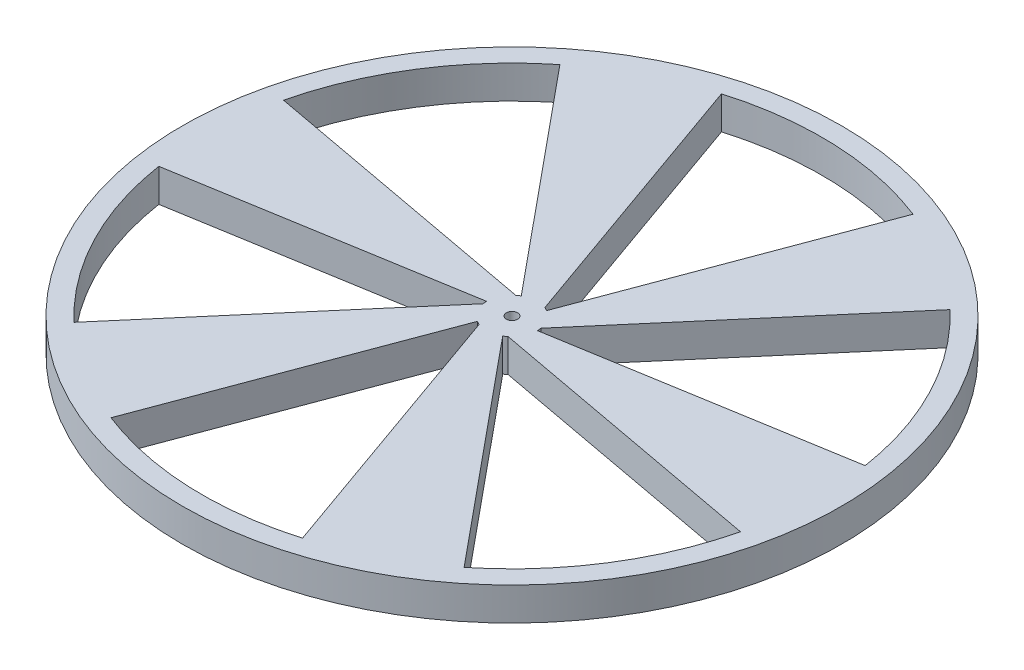
from build123d import *

# Parameters (mm, degrees)
SKETCH1_R           = 50
SKETCH1_R_2         = 47
SKETCH1_R_3         = 3.85
SKETCH1_R_4         = 0.85
BOSS_EXTRUDE1_DEPTH = 5


with BuildPart() as part:
    # Sketch1 → Boss-Extrude1 (new body)
    with BuildSketch(Plane(origin=(0, 0, 0), x_dir=(1, 0, 0), z_dir=(0, 1, 0))):
        Circle(SKETCH1_R)
        Circle(SKETCH1_R_2, mode=Mode.SUBTRACT)
        Circle(SKETCH1_R_3)
        Circle(SKETCH1_R_4, mode=Mode.SUBTRACT)
        with BuildLine():
            ThreePointArc((1.925, -3.334197805), (0.295727162, -3.838625463), (-1.39158336, -3.589706917))
            Line((-1.39158336, -3.589706917), (13.299862292, -45.078971406))
            ThreePointArc((13.299862292, -45.078971406), (21.761273299, -41.658696384), (29.402141879, -36.667615861))
            Line((29.402141879, -36.667615861), (1.925, -3.334197805))
        make_face()
        with BuildLine():
            Line((46.456157771, 7.129193862), (3.85, 0))
            ThreePointArc((3.85, 0), (3.472210748, -1.663205496), (2.412985702, -3))
            Line((2.412985702, -3), (45.68946556, -11.021467091))
            ThreePointArc((45.68946556, -11.021467091), (46.671216404, -5.549554878), (47, 0))
            ThreePointArc((47, 0), (46.86384222, 3.574953479), (46.456157771, 7.129193862))
        make_face()
        with BuildLine():
            Line((17.054015892, 43.796809723), (1.925, 3.334197805))
            ThreePointArc((1.925, 3.334197805), (3.176483585, 2.175419967), (3.804569063, 0.589706917))
            Line((3.804569063, 0.589706917), (32.389603268, 34.057504315))
            ThreePointArc((32.389603268, 34.057504315), (25.196852708, 39.675163687), (17.054015892, 43.796809723))
        make_face()
        with BuildLine():
            Line((-29.402141879, 36.667615861), (-1.925, 3.334197805))
            ThreePointArc((-1.925, 3.334197805), (-0.295727162, 3.838625463), (1.39158336, 3.589706917))
            Line((1.39158336, 3.589706917), (-13.299862292, 45.078971406))
            ThreePointArc((-13.299862292, 45.078971406), (-21.761273299, 41.658696384), (-29.402141879, 36.667615861))
        make_face()
        with BuildLine():
            ThreePointArc((-3.85, 0), (-3.472210748, 1.663205496), (-2.412985702, 3))
            Line((-2.412985702, 3), (-45.68946556, 11.021467091))
            ThreePointArc((-45.68946556, 11.021467091), (-46.958126006, 1.983532697), (-46.456157771, -7.129193862))
            Line((-46.456157771, -7.129193862), (-3.85, 0))
        make_face()
        with BuildLine():
            ThreePointArc((-1.925, -3.334197805), (-3.176483585, -2.175419967), (-3.804569063, -0.589706917))
            Line((-3.804569063, -0.589706917), (-32.389603268, -34.057504315))
            ThreePointArc((-32.389603268, -34.057504315), (-25.196852708, -39.675163687), (-17.054015892, -43.796809723))
            Line((-17.054015892, -43.796809723), (-1.925, -3.334197805))
        make_face()
    extrude(amount=BOSS_EXTRUDE1_DEPTH)


solid = part.part
